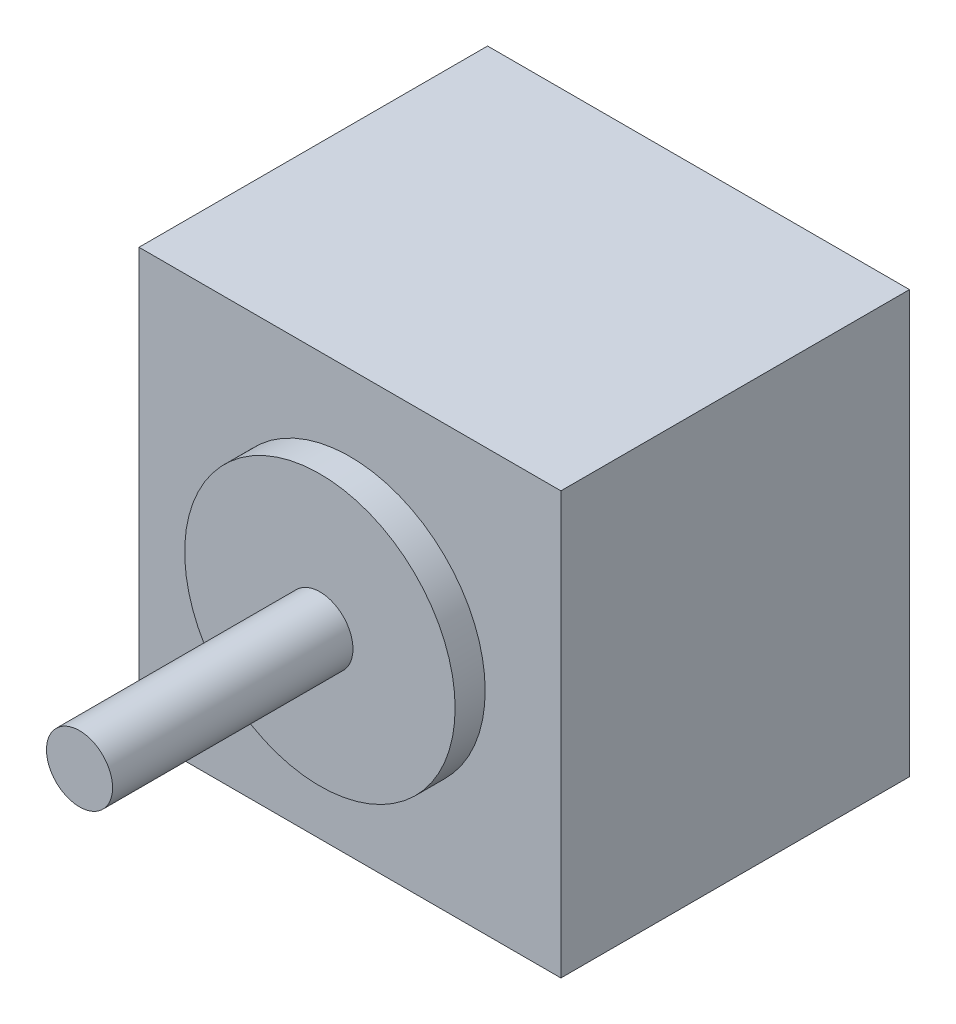
from build123d import *

# Parameters (mm, degrees)
SKETCH1_W           = 35.1
SKETCH1_H           = 35.1
BOSS_EXTRUDE1_DEPTH = 29
SKETCH2_R           = 11.25
BOSS_EXTRUDE2_DEPTH = 2.5
SKETCH3_R           = 2.75
BOSS_EXTRUDE3_DEPTH = 20


with BuildPart() as part:
    # Sketch1 → Boss-Extrude1 (new body)
    with BuildSketch(Plane.XY):
        with Locations((4.3875, -9)):
            Rectangle(SKETCH1_W, SKETCH1_H)
    extrude(amount=BOSS_EXTRUDE1_DEPTH)

    # Sketch2 → Boss-Extrude2 (add)
    with BuildSketch(Plane.XY.offset(29)):
        with Locations((4.3875, -9)):
            Circle(SKETCH2_R)
    extrude(amount=BOSS_EXTRUDE2_DEPTH)

    # Sketch3 → Boss-Extrude3 (add)
    with BuildSketch(Plane.XY.offset(31.5)):
        with Locations((4.3875, -9)):
            Circle(SKETCH3_R)
    extrude(amount=BOSS_EXTRUDE3_DEPTH)


solid = part.part
